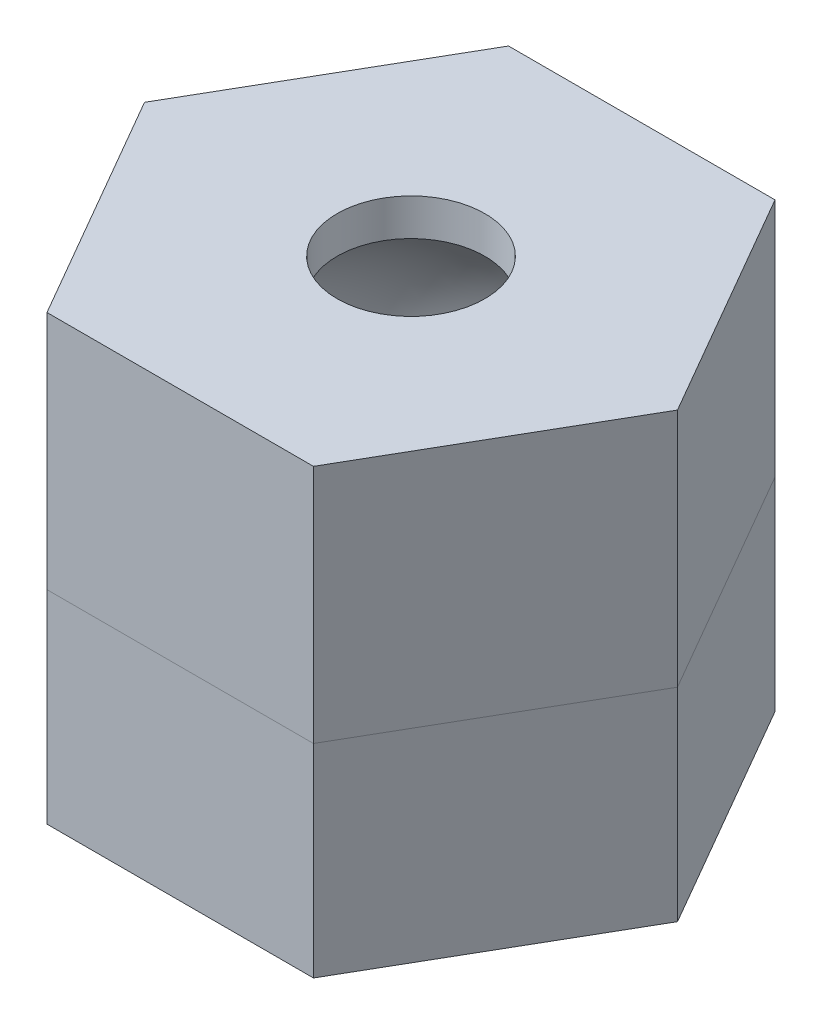
from build123d import *

# Parameters (mm, degrees)
BOSS_DEPTH      = 110
SKETCH6_R       = 5
TAB_HOLES_DEPTH = 11
SKETCH7_R       = 4.5
TABS_DEPTH      = 10
SKETCH8_R       = 20
SPOUT_DEPTH     = 10


with BuildPart() as part:
    # Sketch2 → Boss (new body)
    with BuildSketch(Plane(origin=(0, 0, 0), x_dir=(1, 0, 0), z_dir=(0, 1, 0))):
        Polygon((72.168783649, 0), (36.084391824, 62.5), (-36.084391824, 62.5), (-72.168783649, 0), (-36.084391824, -62.5), (36.084391824, -62.5), align=None)
    extrude(amount=BOSS_DEPTH)

    # Sketch3 → Void (revolve, cut)
    with BuildSketch(Plane(origin=(0, 0, 0), x_dir=(0, 0, -1), z_dir=(1, 0, 0))):
        with BuildLine():
            Line((0, 110), (0, 7.53049234))
            Line((0, 7.53049234), (20, 7.53049234))
            ThreePointArc((20, 7.53049234), (55, 58.76524617), (20, 110))
            Line((20, 110), (0, 110))
        make_face()
    revolve(axis=Axis((0, 110, 0), (0, -1, 0)), mode=Mode.SUBTRACT)


with BuildPart() as body_2:
    # Split 2: the piece on the far side of the plane
    add(part.part)
    split(bisect_by=Plane.ZX.offset(55), keep=Keep.BOTTOM)

    # Sketch7 → Tabs (add)
    with BuildSketch(Plane(origin=(0, 55, 0), x_dir=(1, 0, 0), z_dir=(0, 1, 0))):
        with Locations((62.5, 0)):
            Circle(SKETCH7_R)
        with Locations((31.25, -54.126587737)):
            Circle(SKETCH7_R)
        with Locations((-31.25, -54.126587737)):
            Circle(SKETCH7_R)
        with Locations((-62.5, 0)):
            Circle(SKETCH7_R)
        with Locations((-31.25, 54.126587737)):
            Circle(SKETCH7_R)
        with Locations((31.25, 54.126587737)):
            Circle(SKETCH7_R)
    extrude(amount=TABS_DEPTH)


with BuildPart() as part_1:
    add(part.part)

    # Split 2
    split(bisect_by=Plane.ZX.offset(55), keep=Keep.TOP)

    # Sketch6 → Tab Holes (cut)
    with BuildSketch(Plane(origin=(0, 55, 0), x_dir=(1, 0, 0), z_dir=(0, 1, 0))):
        with Locations((62.5, 0)):
            Circle(SKETCH6_R)
        with Locations((31.25, -54.126587737)):
            Circle(SKETCH6_R)
        with Locations((-31.25, -54.126587737)):
            Circle(SKETCH6_R)
        with Locations((-62.5, 0)):
            Circle(SKETCH6_R)
        with Locations((-31.25, 54.126587737)):
            Circle(SKETCH6_R)
        with Locations((31.25, 54.126587737)):
            Circle(SKETCH6_R)
    extrude(amount=TAB_HOLES_DEPTH, mode=Mode.SUBTRACT)

    # Sketch8 → Spout (add)
    with BuildSketch(Plane(origin=(0, 110, 0), x_dir=(1, 0, 0), z_dir=(0, 1, 0))):
        Polygon((36.084391824, -62.5), (72.168783649, 0), (36.084391824, 62.5), (-36.084391824, 62.5), (-72.168783649, 0), (-36.084391824, -62.5), align=None)
        Circle(SKETCH8_R, mode=Mode.SUBTRACT)
    extrude(amount=SPOUT_DEPTH)


solid = Compound([body_2.part, part_1.part])
